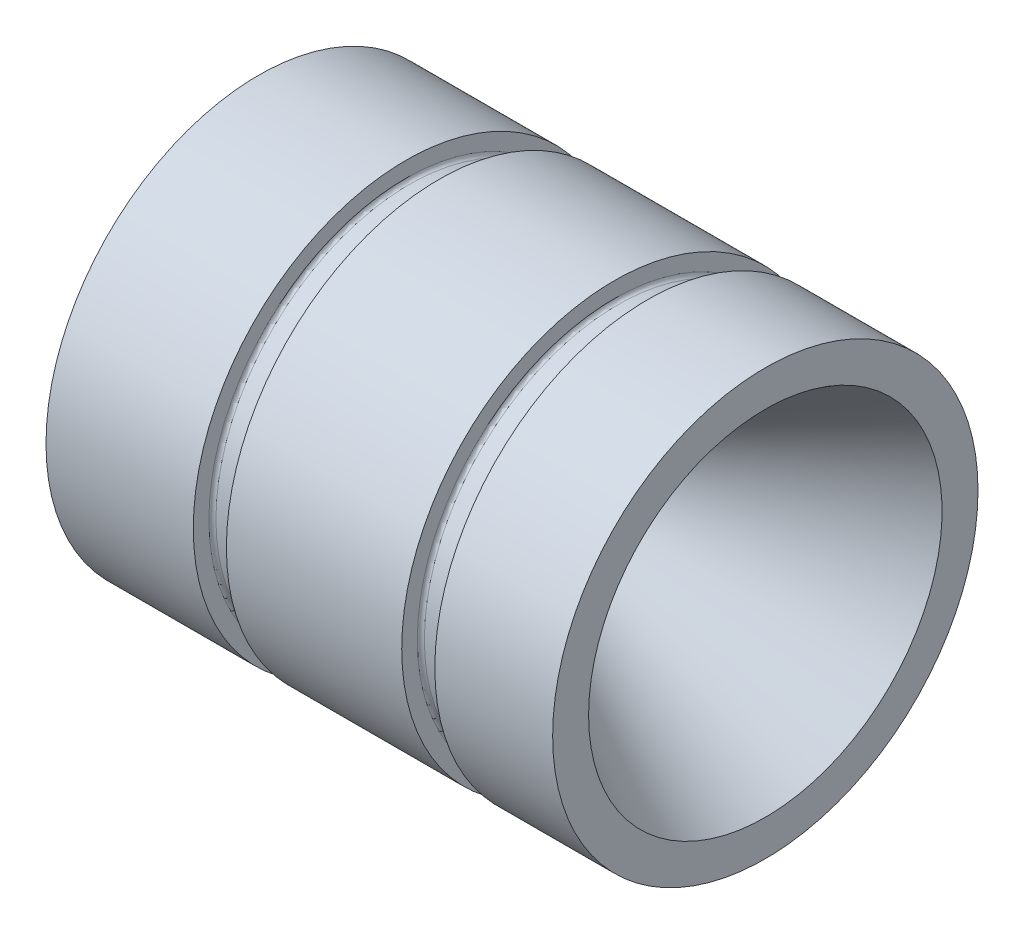
from build123d import *

# Parameters (mm, degrees)
SKETCH1_R           = 45.847
BOSS_EXTRUDE1_DEPTH = 109.22


with BuildPart() as part:
    # Sketch1 → Boss-Extrude1 (new body)
    with BuildSketch(Plane(origin=(0, 0, 0), x_dir=(0, 0, -1), z_dir=(1, 0, 0))):
        Circle(SKETCH1_R)
    extrude(amount=BOSS_EXTRUDE1_DEPTH)

    # Sketch3 → Cut-Revolve1 (revolve, cut)
    with BuildSketch(Plane.XY):
        Polygon((0, 0), (0, 28.321), (58.298365665, 12.7), (64.77, 12.7), (109.22, 38.1), (109.22, 0), align=None)
    revolve(axis=Axis((0, 0, 0), (1, 0, 0)), mode=Mode.SUBTRACT)

    # Sketch4 → Cut-Revolve2 (revolve, cut)
    with BuildSketch(Plane.XY):
        with BuildLine():
            Line((76.6826, 45.847), (83.82, 45.847))
            Line((83.82, 45.847), (83.82, 42.4815))
            ThreePointArc((83.82, 42.4815), (83.596815367, 41.942684633), (83.058, 41.7195))
            Line((83.058, 41.7195), (77.4446, 41.7195))
            ThreePointArc((77.4446, 41.7195), (76.905784633, 41.942684633), (76.6826, 42.4815))
            Line((76.6826, 42.4815), (76.6826, 45.847))
        make_face()
        with BuildLine():
            Line((31.75, 45.847), (38.8874, 45.847))
            Line((38.8874, 45.847), (38.8874, 42.4815))
            ThreePointArc((38.8874, 42.4815), (38.664215367, 41.942684633), (38.1254, 41.7195))
            Line((38.1254, 41.7195), (32.512, 41.7195))
            ThreePointArc((32.512, 41.7195), (31.973184633, 41.942684633), (31.75, 42.4815))
            Line((31.75, 42.4815), (31.75, 45.847))
        make_face()
    revolve(axis=Axis((0, 0, 0), (-1, 0, 0)), mode=Mode.SUBTRACT)


solid = part.part
